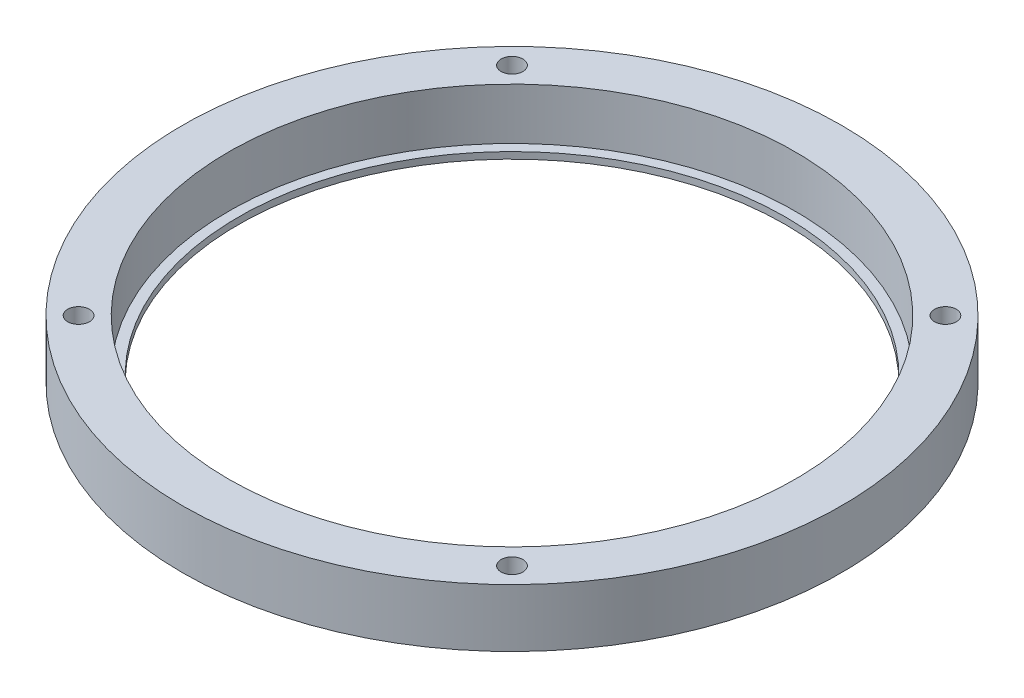
from build123d import *

# Parameters (mm, degrees)
SKETCH_2_R         = 50
SKETCH_2_R_2       = 43
EXTRUDE_1_DEPTH    = 7.8
SKETCH_3_R         = 50
SKETCH_3_R_2       = 41.5
EXTRUDE_2_DEPTH    = 1
HOLE_WIZARD_M4_1_D = 3.3


with BuildPart() as part:
    # 草图2 → 凸台-拉伸1 (new body)
    with BuildSketch(Plane(origin=(0, 0, 0), x_dir=(1, 0, 0), z_dir=(0, 1, 0))):
        Circle(SKETCH_2_R)
        Circle(SKETCH_2_R_2, mode=Mode.SUBTRACT)
    extrude(amount=EXTRUDE_1_DEPTH)

    # 草图3 → 凸台-拉伸2 (add)
    with BuildSketch(Plane.XZ):
        Circle(SKETCH_3_R)
        Circle(SKETCH_3_R_2, mode=Mode.SUBTRACT)
    extrude(amount=EXTRUDE_2_DEPTH)

    # M4 螺纹孔1 (through all)
    with Locations(Plane(origin=(0, 7.8, 0), x_dir=(1, 0, 0), z_dir=(0, 1, 0))):
        with Locations((-32.880465325, 32.880465325), (-32.880465325, -32.880465325), (32.880465325, -32.880465325), (32.880465325, 32.880465325)):
            Hole(HOLE_WIZARD_M4_1_D / 2)


solid = part.part
